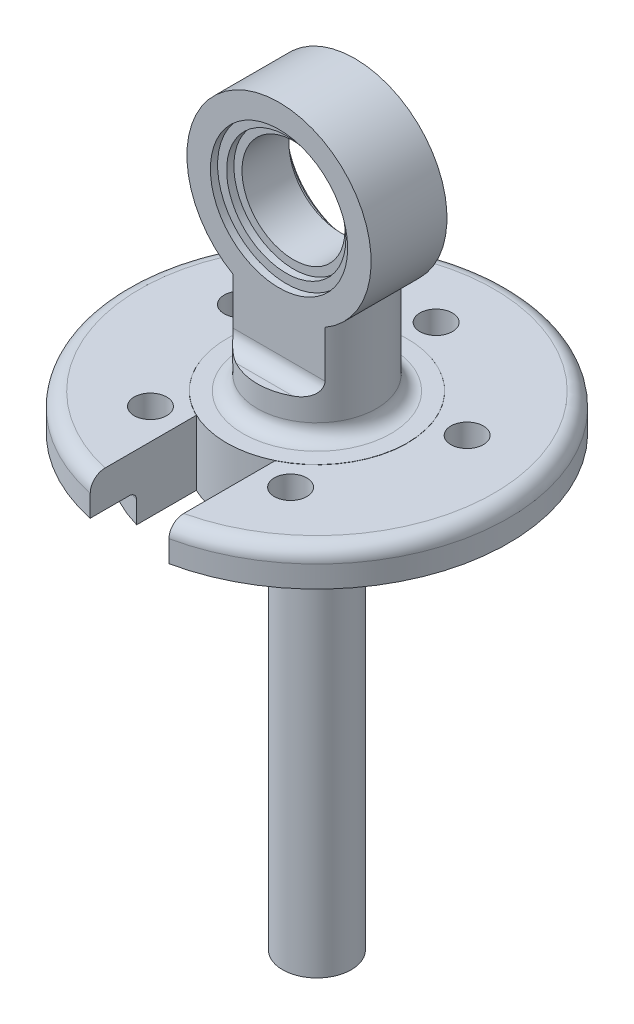
from build123d import *

# Parameters (mm, degrees)
SKETCH1_R           = 4.75
BOSS_EXTRUDE1_DEPTH = 58
SKETCH2_R           = 9.45
BOSS_EXTRUDE2_DEPTH = 2.5
SKETCH3_R           = 20.25
BOSS_EXTRUDE3_DEPTH = 4
SKETCH4_R           = 26.5
BOSS_EXTRUDE4_DEPTH = 5
FILLET2_R           = 1
FILLET3_R           = 2
SKETCH7_R           = 8.25
BOSS_EXTRUDE5_DEPTH = 3.5
SKETCH6_R           = 12.5
BOSS_EXTRUDE6_DEPTH = 0.03
FILLET4_R           = 2
CUT_EXTRUDE2_REACH  = 78.769
SKETCH10_R          = 2.25
CIRPATTERN2_COUNT   = 5
CUT_EXTRUDE3_REACH  = 78.769
SKETCH12_R          = 8.25
BOSS_EXTRUDE7_DEPTH = 11.5
SKETCH14_W          = 46.141054865
SKETCH14_H          = 36.084049614
CUT_EXTRUDE4_DEPTH  = 3
SKETCH15_W          = 46.141054865
SKETCH15_H          = 36.084049614
CUT_EXTRUDE6_DEPTH  = 3
FILLET5_R           = 2
FILLET6_R           = 2
SKETCH16_R          = 12.75
BOSS_EXTRUDE8_DEPTH = 10.5
SKETCH17_R          = 9.5
CUT_EXTRUDE9_DEPTH  = 1
SKETCH18_R          = 8.25
CUT_EXTRUDE10_DEPTH = 1
CUT_EXTRUDE11_REACH = 113.604
SKETCH19_R          = 7.125


with BuildPart() as part:
    # Sketch1 → Boss-Extrude1 (new body)
    with BuildSketch(Plane(origin=(0, 0, 0), x_dir=(1, 0, 0), z_dir=(0, 1, 0))):
        Circle(SKETCH1_R)
    extrude(amount=BOSS_EXTRUDE1_DEPTH)

    # Sketch2 → Boss-Extrude2 (add)
    with BuildSketch(Plane(origin=(0, 58, 0), x_dir=(1, 0, 0), z_dir=(0, 1, 0))):
        Circle(SKETCH2_R)
    extrude(amount=-BOSS_EXTRUDE2_DEPTH)

    # Sketch3 → Boss-Extrude3 (add)
    with BuildSketch(Plane(origin=(0, 58, 0), x_dir=(1, 0, 0), z_dir=(0, 1, 0))):
        Circle(SKETCH3_R)
    extrude(amount=BOSS_EXTRUDE3_DEPTH)

    # Sketch4 → Boss-Extrude4 (add)
    with BuildSketch(Plane(origin=(0, 62, 0), x_dir=(1, 0, 0), z_dir=(0, 1, 0))):
        Circle(SKETCH4_R)
    extrude(amount=BOSS_EXTRUDE4_DEPTH)

    # Fillet2
    fillet2_edges = [part.edges().sort_by_distance(p)[0] for p in [
        (-20.25, 62, 0),
    ]]
    fillet(fillet2_edges, radius=FILLET2_R)

    # Fillet3
    fillet3_edges = [part.edges().sort_by_distance(p)[0] for p in [
        (-26.5, 67, 0),
    ]]
    fillet(fillet3_edges, radius=FILLET3_R)

    # Sketch7 → Boss-Extrude5 (add)
    with BuildSketch(Plane(origin=(0, 67, 0), x_dir=(1, 0, 0), z_dir=(0, 1, 0))):
        Circle(SKETCH7_R)
    boss_extrude5 = extrude(amount=BOSS_EXTRUDE5_DEPTH)

    # Sketch6 → Boss-Extrude6 (add)
    with BuildSketch(Plane(origin=(0, 67, 0), x_dir=(1, 0, 0), z_dir=(0, 1, 0))):
        Circle(SKETCH6_R)
    extrude(amount=BOSS_EXTRUDE6_DEPTH)

    # Fillet4
    fillet4_edges = [part.edges().sort_by_distance(p)[0] for p in [
        (-8.25, 67.03, 0),
    ]]
    fillet(fillet4_edges, radius=FILLET4_R)

    # Sketch10 → Cut-Extrude2 (cut, up to next)
    with BuildSketch(Plane(origin=(0, 67, 0), x_dir=(1, 0, 0), z_dir=(0, 1, 0)), mode=Mode.PRIVATE) as cut_extrude2_sk1:
        with Locations((0, 16.5)):
            Circle(SKETCH10_R)
    cut_extrude2_tool1 = extrude(cut_extrude2_sk1.sketch, amount=-CUT_EXTRUDE2_REACH, mode=Mode.PRIVATE) & part.part
    cut_extrude2 = cut_extrude2_tool1.solids().sort_by_distance((0, 67, -16.5))[0]
    add(cut_extrude2, mode=Mode.SUBTRACT)

    # CirPattern2: Boss-Extrude5, Cut-Extrude2 ×5 about axis
    cirpattern2_axis = Axis((0, 67, 0), (0, 1, 0))
    add([boss_extrude5.rotate(cirpattern2_axis, i * 360 / CIRPATTERN2_COUNT) for i in range(1, CIRPATTERN2_COUNT)])
    add([cut_extrude2.rotate(cirpattern2_axis, i * 360 / CIRPATTERN2_COUNT) for i in range(1, CIRPATTERN2_COUNT)], mode=Mode.SUBTRACT)

    # Sketch11 → Cut-Extrude3 (cut, up to next)
    with BuildSketch(Plane(origin=(0, 67, 0), x_dir=(1, 0, 0), z_dir=(0, 1, 0)), mode=Mode.PRIVATE) as cut_extrude3_sk1:
        with BuildLine():
            Line((-5.448456663, -13.348780407), (-5.448456663, -11.250080888))
            ThreePointArc((-5.448456663, -11.250080888), (0, -12.5), (5.448456663, -11.250080888))
            Line((5.448456663, -11.250080888), (5.448456663, -13.348780407))
            Line((5.448456663, -13.348780407), (5.448456663, -26.5))
            Line((5.448456663, -26.5), (-5.448456663, -26.5))
            Line((-5.448456663, -26.5), (-5.448456663, -13.348780407))
        make_face()
    cut_extrude3_tool1 = extrude(cut_extrude3_sk1.sketch, amount=-CUT_EXTRUDE3_REACH, mode=Mode.PRIVATE) & part.part
    add(cut_extrude3_tool1.solids().sort_by_distance((0, 67, 19.291289))[0], mode=Mode.SUBTRACT)

    # Sketch12 → Boss-Extrude7 (add)
    with BuildSketch(Plane(origin=(0, 70.5, 0), x_dir=(1, 0, 0), z_dir=(0, 1, 0))):
        Circle(SKETCH12_R)
    extrude(amount=BOSS_EXTRUDE7_DEPTH)

    # Sketch14 → Cut-Extrude4 (cut)
    with BuildSketch(Plane.XY.offset(8.25)):
        with Locations((-0.297638502, 90.042024807)):
            Rectangle(SKETCH14_W, SKETCH14_H)
    extrude(amount=-CUT_EXTRUDE4_DEPTH, mode=Mode.SUBTRACT)

    # Sketch15 → Cut-Extrude6 (cut)
    with BuildSketch(Plane.XY.offset(-8.25)):
        with Locations((-0.297638502, 90.042024807)):
            Rectangle(SKETCH15_W, SKETCH15_H)
    extrude(amount=CUT_EXTRUDE6_DEPTH, mode=Mode.SUBTRACT)

    # Fillet5
    fillet5_edges = [part.edges().sort_by_distance(p)[0] for p in [
        (0, 72, -5.25),
    ]]
    fillet(fillet5_edges, radius=FILLET5_R)

    # Fillet6
    fillet6_edges = [part.edges().sort_by_distance(p)[0] for p in [
        (0, 72, 5.25),
    ]]
    fillet(fillet6_edges, radius=FILLET6_R)

    # Sketch16 → Boss-Extrude8 (add)
    with BuildSketch(Plane.XY.offset(5.25)):
        with Locations((0, 91.5)):
            Circle(SKETCH16_R)
    extrude(amount=-BOSS_EXTRUDE8_DEPTH)

    # Sketch17 → Cut-Extrude9 (cut)
    with BuildSketch(Plane.XY.offset(5.25)):
        with Locations((0, 91.5)):
            Circle(SKETCH17_R)
    cut_extrude9 = extrude(amount=-CUT_EXTRUDE9_DEPTH, mode=Mode.SUBTRACT)

    # Sketch18 → Cut-Extrude10 (cut)
    with BuildSketch(Plane.XY.offset(4.25)):
        with Locations((0, 91.5)):
            Circle(SKETCH18_R)
    cut_extrude10 = extrude(amount=-CUT_EXTRUDE10_DEPTH, mode=Mode.SUBTRACT)

    # Sketch19 → Cut-Extrude11 (cut, up to next)
    with BuildSketch(Plane.XY.offset(3.25), mode=Mode.PRIVATE) as cut_extrude11_sk1:
        with Locations((0, 91.5)):
            Circle(SKETCH19_R)
    cut_extrude11_tool1 = extrude(cut_extrude11_sk1.sketch, amount=-CUT_EXTRUDE11_REACH, mode=Mode.PRIVATE) & part.part
    add(cut_extrude11_tool1.solids().sort_by_distance((0, 91.5, 3.25))[0], mode=Mode.SUBTRACT)

    # Mirror1: Cut-Extrude9 across plane
    add(cut_extrude9.mirror(Plane.XY), mode=Mode.SUBTRACT)

    # Mirror2: Cut-Extrude10 across plane
    add(cut_extrude10.mirror(Plane.XY), mode=Mode.SUBTRACT)


solid = part.part
